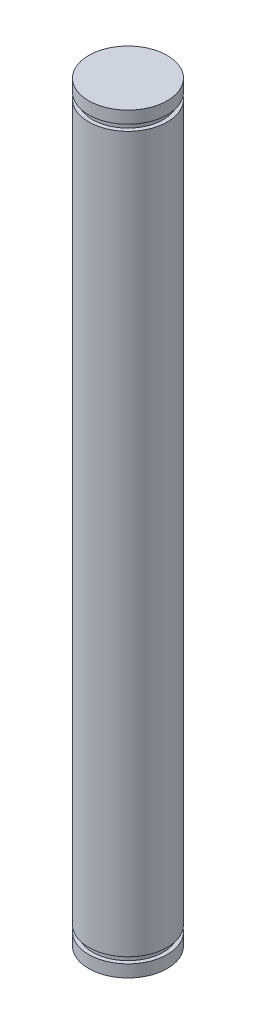
from build123d import *

# Parameters (mm, degrees)
SKETCH1_R           = 6.35
SKETCH1_R_2         = 3.175
BOSS_EXTRUDE1_DEPTH = 59.69
CUT_EXTRUDE1_START  = 1.905
SKETCH2_R           = 6.35
SKETCH2_R_2         = 5.715
CUT_EXTRUDE1_DEPTH  = 0.9906
SKETCH3_R           = 6.35
BOSS_EXTRUDE2_DEPTH = 1.064499902


with BuildPart() as part:
    # Sketch1 → Boss-Extrude1 (new body, symmetric)
    with BuildSketch(Plane(origin=(0, 0, 0), x_dir=(1, 0, 0), z_dir=(0, 1, 0))):
        Circle(SKETCH1_R)
        Circle(SKETCH1_R_2, mode=Mode.SUBTRACT)
        Circle(SKETCH1_R_2)
    extrude(amount=BOSS_EXTRUDE1_DEPTH, both=True)

    # Sketch2 → Cut-Extrude1 (cut)
    with BuildSketch(Plane(origin=(0, -59.69, 0), x_dir=(1, 0, 0), z_dir=(0, 1, 0)).offset(CUT_EXTRUDE1_START)):
        Circle(SKETCH2_R)
        Circle(SKETCH2_R_2, mode=Mode.SUBTRACT)
    cut_extrude1 = extrude(amount=-CUT_EXTRUDE1_DEPTH, mode=Mode.SUBTRACT)

    # Mirror1: Cut-Extrude1 across plane
    add(cut_extrude1.mirror(Plane.ZX), mode=Mode.SUBTRACT)

    # Sketch3 → Boss-Extrude2 (add)
    with BuildSketch(Plane(origin=(0, 59.69, 0), x_dir=(1, 0, 0), z_dir=(0, 1, 0))):
        Circle(SKETCH3_R)
    boss_extrude2 = extrude(amount=BOSS_EXTRUDE2_DEPTH)

    # Mirror2: Boss-Extrude2 across plane
    add(boss_extrude2.mirror(Plane.ZX))


solid = part.part
